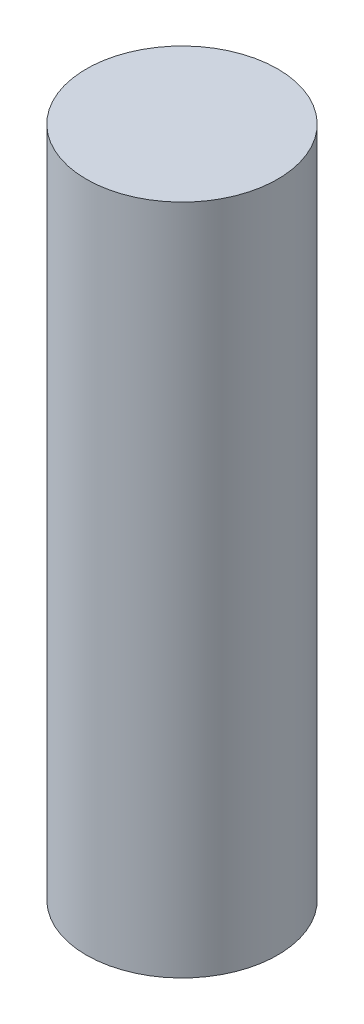
from build123d import *

# Parameters (mm, degrees)
SKETCH1_R           = 9.25
BOSS_EXTRUDE1_DEPTH = 65


with BuildPart() as part:
    # Sketch1 → Boss-Extrude1 (new body)
    with BuildSketch(Plane(origin=(0, 0, 0), x_dir=(1, 0, 0), z_dir=(0, 1, 0))):
        Circle(SKETCH1_R)
    extrude(amount=BOSS_EXTRUDE1_DEPTH)


solid = part.part
